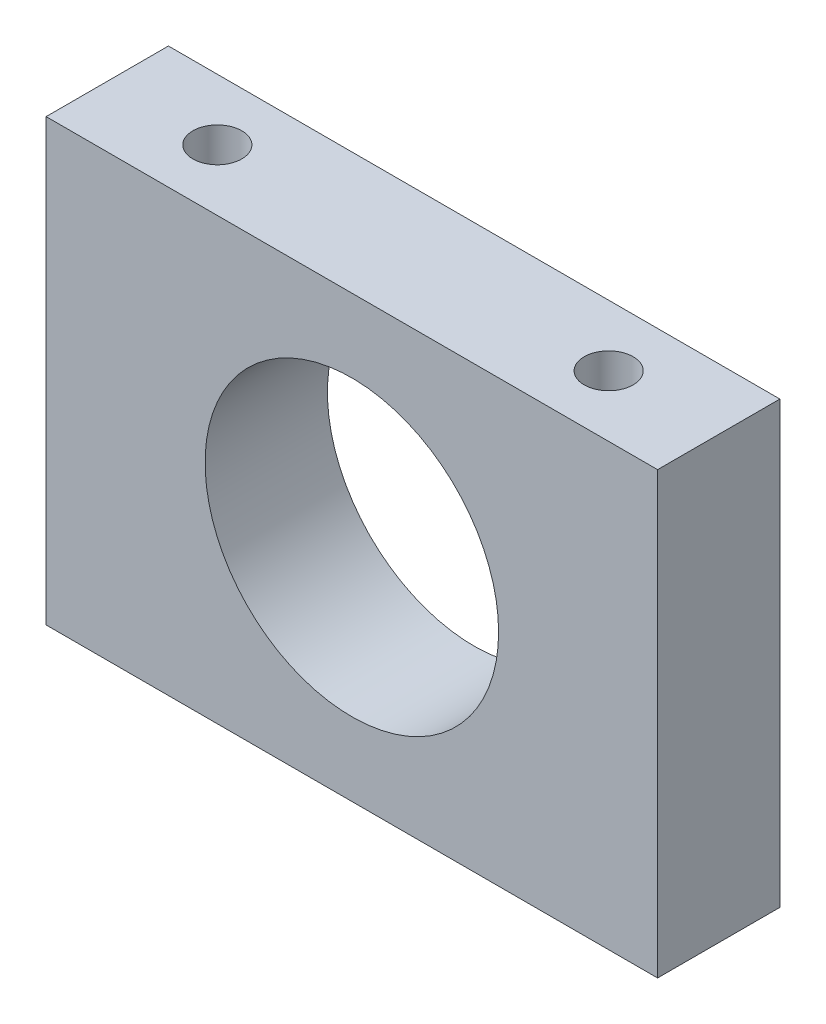
from build123d import *

# Parameters (mm, degrees)
ESQUISSE1_W             = 25
ESQUISSE1_H             = 18
ESQUISSE1_R             = 6
BOSS_EXTRU_1_DEPTH      = 5
ESQUISSE2_R             = 1
ENL_V_MAT_EXTRU_1_DEPTH = 15


with BuildPart() as part:
    # Esquisse1 → Boss.-Extru.1 (new body)
    with BuildSketch(Plane.XY):
        Rectangle(ESQUISSE1_W, ESQUISSE1_H)
        Circle(ESQUISSE1_R, mode=Mode.SUBTRACT)
    extrude(amount=BOSS_EXTRU_1_DEPTH)

    # Esquisse2 → Enlèv. mat.-Extru.1 (cut)
    with BuildSketch(Plane(origin=(0, 9, 0), x_dir=(1, 0, 0), z_dir=(0, 1, 0))):
        with Locations((-8, -2.5)):
            Circle(ESQUISSE2_R)
        with Locations((8, -2.5)):
            Circle(ESQUISSE2_R)
    extrude(amount=-ENL_V_MAT_EXTRU_1_DEPTH, mode=Mode.SUBTRACT)


solid = part.part
